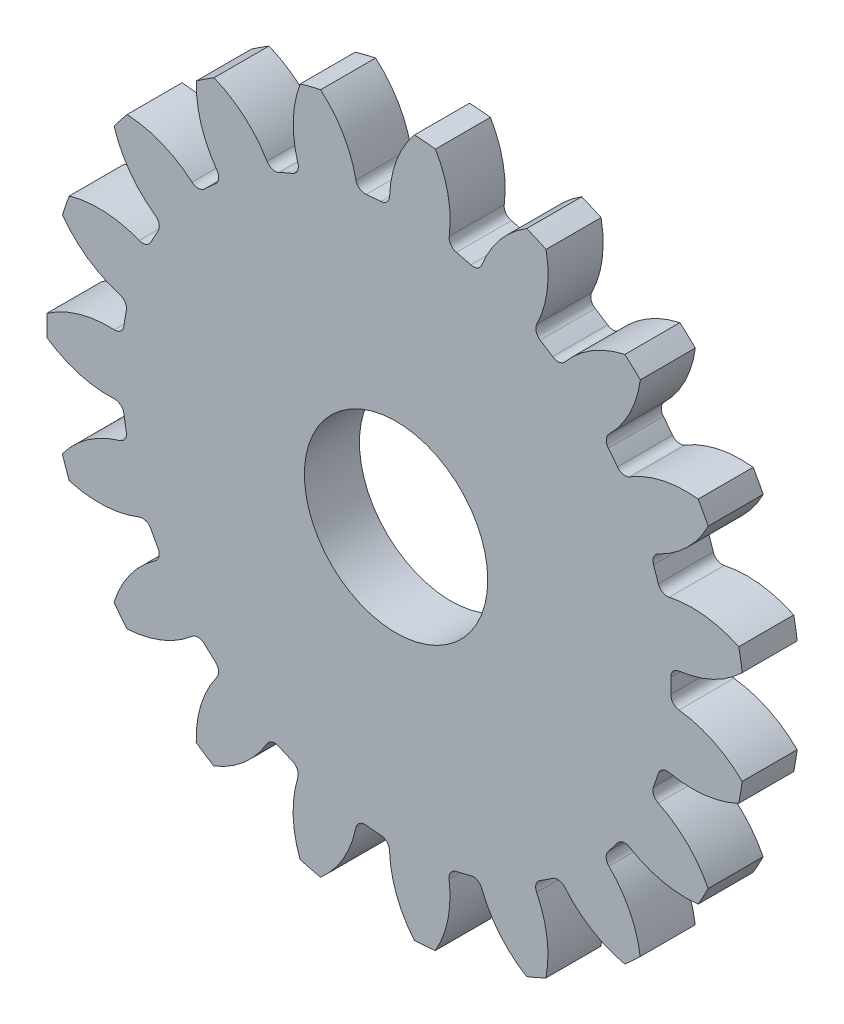
from build123d import *

# Parameters (mm, degrees)
CROQUIS1_R              = 19.05
SALIENTE_EXTRUIR1_DEPTH = 3
CORTAR_EXTRUIR1_DEPTH   = 4
REDONDEO1_R             = 0.508
MATRIZC1_COUNT          = 19
REDONDEO1_OF_MATRIZC1_R = 0.508
CROQUIS3_R              = 5
CORTAR_EXTRUIR2_DEPTH   = 4.0000001


with BuildPart() as part:
    # Croquis1 → Saliente-Extruir1 (new body)
    with BuildSketch(Plane.XY):
        Circle(CROQUIS1_R)
    extrude(amount=SALIENTE_EXTRUIR1_DEPTH)

    # Croquis2 → Cortar-Extruir1 (cut, through all)
    with BuildSketch(Plane.XY.offset(3)):
        with BuildLine():
            ThreePointArc((1.004728891, 19.023486007), (-1.568823529, 18.985291484), (-4.113737743, 18.600528535))
            ThreePointArc((-4.113737743, 18.600528535), (-2.762439281, 16.905013516), (-2.113874916, 14.836162875))
            ThreePointArc((-2.113874916, 14.836162875), (-1.234141176, 14.935095967), (-0.350100645, 14.981909943))
            ThreePointArc((-0.350100645, 14.981909943), (-0.04992783, 17.12915818), (1.004728891, 19.023486007))
        make_face()
    cortar_extruir1 = extrude(amount=-CORTAR_EXTRUIR1_DEPTH, mode=Mode.SUBTRACT)

    # Redondeo1
    redondeo1_edges = [part.edges().sort_by_distance(p)[0] for p in [
        (-0.350100645, 14.981909943, 1.5),
        (-2.113874916, 14.836162875, 1.5),
    ]]
    fillet(redondeo1_edges, radius=REDONDEO1_R)

    # MatrizC1: Cortar-Extruir1 ×19 about axis
    matrizc1_axis = Axis((0, 0, 0), (0, 0, 1))
    for i in range(1, MATRIZC1_COUNT):
        add(cortar_extruir1.rotate(matrizc1_axis, i * 360 / MATRIZC1_COUNT), mode=Mode.SUBTRACT)

    # Redondeo1 of MatrizC1
    redondeo1_of_matrizc1_edges = [part.edges().sort_by_distance(p)[0] for p in [
        (-5.195749433, 14.056471244, 1.5),
        (-6.816633553, 13.345924584, 1.5),
        (-9.478358149, 11.607795777, 1.5),
        (-10.780704173, 10.409448282, 1.5),
        (-12.733839688, 7.901235524, 1.5),
        (-13.576518216, 6.344946739, 1.5),
        (-14.60941211, 3.338453802, 1.5),
        (-14.90110585, 1.592871765, 1.5),
        (-14.901828043, -1.586101191, 1.5),
        (-14.61092745, -3.331815581, 1.5),
        (-13.579399681, -6.338777509, 1.5),
        (-12.737428348, -7.89544901, 1.5),
        (-10.785432657, -10.404548928, 1.5),
        (-9.483631244, -11.603488028, 1.5),
        (-6.822696652, -13.342826027, 1.5),
        (-5.202135541, -14.054109072, 1.5),
        (-2.1206156, -14.835200891, 1.5),
        (-0.356907732, -14.981749326, 1.5),
        (2.811267058, -14.719951547, 1.5),
        (4.526996567, -14.285884575, 1.5),
        (7.438505308, -13.009567048, 1.5),
        (8.920330545, -12.041922561, 1.5),
        (11.259666088, -9.889394096, 1.5),
        (12.347008295, -8.493031389, 1.5),
        (13.860667335, -5.697551844, 1.5),
        (14.435696112, -4.023788482, 1.5),
        (14.959650207, -0.888291443, 1.5),
        (14.960052263, 0.881494342, 1.5),
        (14.437522855, 4.017229119, 1.5),
        (13.863254623, 5.691253576, 1.5),
        (12.350865881, 8.487420573, 1.5),
        (11.264158233, 9.884277177, 1.5),
        (8.925800946, 12.037868311, 1.5),
        (7.444415517, 13.006185975, 1.5),
        (4.533486979, 14.283826231, 1.5),
        (2.817954868, 14.718672711, 1.5),
    ]]
    fillet(redondeo1_of_matrizc1_edges, radius=REDONDEO1_OF_MATRIZC1_R)

    # Croquis3 → Cortar-Extruir2 (cut, through all)
    with BuildSketch(Plane.XY.offset(3)):
        Circle(CROQUIS3_R)
    extrude(amount=-CORTAR_EXTRUIR2_DEPTH, mode=Mode.SUBTRACT)


solid = part.part
